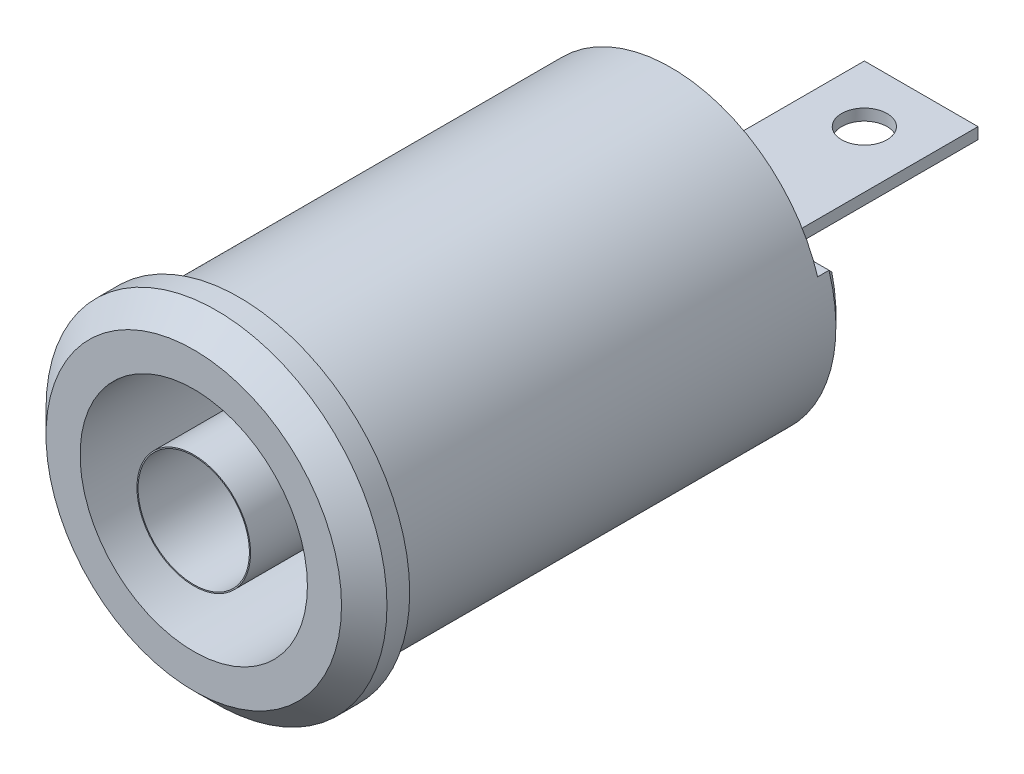
from build123d import *

# Parameters (mm, degrees)
ESQUISSE1_R           = 7.5
EXTRUSION1_DEPTH      = 32
ESQUISSE2_R           = 5
ESQUISSE2_R_2         = 2.5
ESQUISSE2_R_3         = 2.45
EXTRUSION3_DEPTH      = 18
ESQUISSE3_OUTSIDE_W   = 24.678
ESQUISSE3_OUTSIDE_H   = 24.678
ESQUISSE3_OUTSIDE_R   = 6.75
EXTRUSION5_DEPTH      = 30
ESQUISSE4_OUTSIDE_W   = 24.678
ESQUISSE4_OUTSIDE_H   = 24.678
ESQUISSE4_OUTSIDE_W_2 = 5
ESQUISSE4_OUTSIDE_H_2 = 0.5
EXTRUSION6_DEPTH      = 10
ESQUISSE5_W           = 18
ESQUISSE5_H           = 6
EXTRUSION7_DEPTH      = 1
ESQUISSE6_R           = 1
EXTRUSION8_DEPTH      = 8.75
CHANFREIN1_SIZE       = 1
CHANFREIN2_SIZE       = 0.5


with BuildPart() as part:
    # Esquisse1 → Extrusion1 (new body)
    with BuildSketch(Plane.XY):
        Circle(ESQUISSE1_R)
    extrude(amount=-EXTRUSION1_DEPTH)

    # Esquisse2 → Extrusion3 (cut)
    with BuildSketch(Plane.XY):
        Circle(ESQUISSE2_R)
        Circle(ESQUISSE2_R_2, mode=Mode.SUBTRACT)
        Circle(ESQUISSE2_R_3)
    extrude(amount=-EXTRUSION3_DEPTH, mode=Mode.SUBTRACT)

    # Esquisse3 outside → Extrusion5 (cut)
    with BuildSketch(Plane(origin=(0, 0, -32), x_dir=(-1, 0, 0), z_dir=(0, 0, -1))):
        Rectangle(ESQUISSE3_OUTSIDE_W, ESQUISSE3_OUTSIDE_H)
        Circle(ESQUISSE3_OUTSIDE_R, mode=Mode.SUBTRACT)
    extrude(amount=-EXTRUSION5_DEPTH, mode=Mode.SUBTRACT)

    # Esquisse4 outside → Extrusion6 (cut)
    with BuildSketch(Plane(origin=(0, 0, -32), x_dir=(-1, 0, 0), z_dir=(0, 0, -1))):
        Rectangle(ESQUISSE4_OUTSIDE_W, ESQUISSE4_OUTSIDE_H)
        Rectangle(ESQUISSE4_OUTSIDE_W_2, ESQUISSE4_OUTSIDE_H_2, mode=Mode.SUBTRACT)
    extrude(amount=-EXTRUSION6_DEPTH, mode=Mode.SUBTRACT)

    # Esquisse5 → Extrusion7 (cut)
    with BuildSketch(Plane(origin=(0, 0, -22), x_dir=(-1, 0, 0), z_dir=(0, 0, -1))):
        with Locations((0, 5)):
            Rectangle(ESQUISSE5_W, ESQUISSE5_H)
    extrude(amount=-EXTRUSION7_DEPTH, mode=Mode.SUBTRACT)

    # Esquisse6 → Extrusion8 (cut, through all)
    with BuildSketch(Plane(origin=(0, 0.25, 0), x_dir=(1, 0, 0), z_dir=(0, 1, 0))):
        with Locations((0, 29.5)):
            Circle(ESQUISSE6_R)
    extrude(amount=-EXTRUSION8_DEPTH, mode=Mode.SUBTRACT)

    # Chanfrein1
    chanfrein1_edges = [part.edges().sort_by_distance(p)[0] for p in [
        (-7.5, 0, 0),
    ]]
    chamfer(chanfrein1_edges, length=CHANFREIN1_SIZE)

    # Chanfrein2
    chanfrein2_edges = [part.edges().sort_by_distance(p)[0] for p in [
        (1.011418624, -6.67379445, -22),
        (0, 2, -22),
    ]]
    chamfer(chanfrein2_edges, length=CHANFREIN2_SIZE)


solid = part.part
